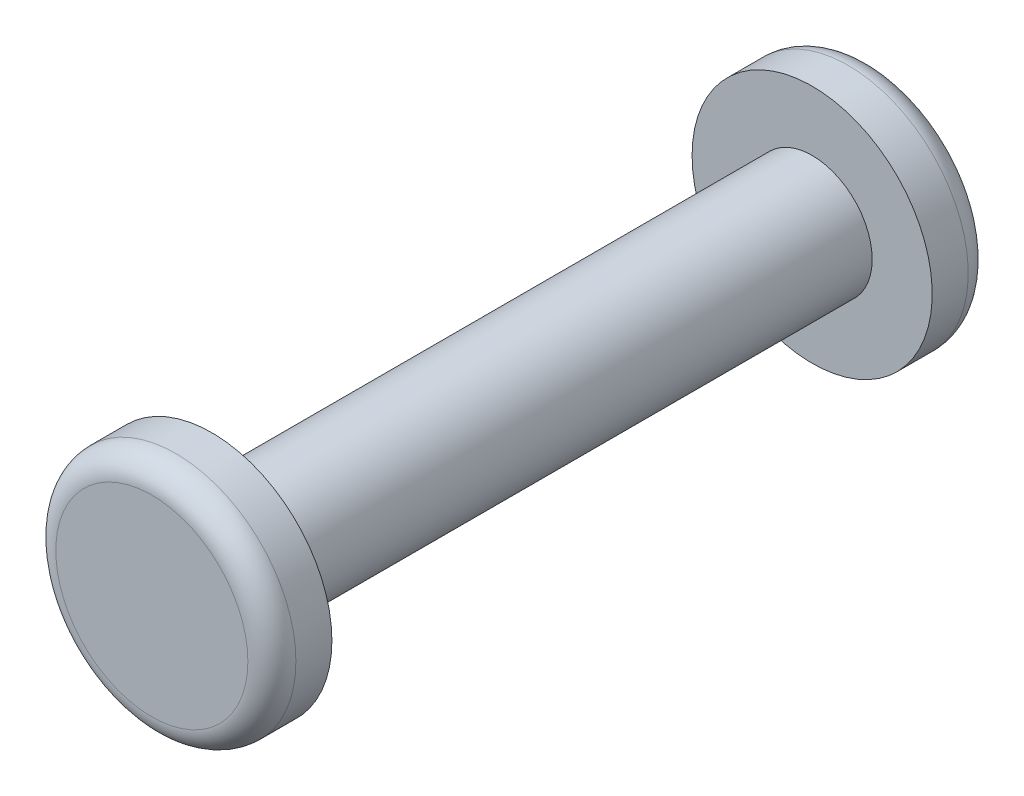
from build123d import *

# Parameters (mm, degrees)
SKETCH1_R           = 5
BOSS_EXTRUDE1_DEPTH = 25
SKETCH2_R           = 10
BOSS_EXTRUDE2_DEPTH = 5
SKETCH3_R           = 10
BOSS_EXTRUDE3_DEPTH = 5
FILLET1_R           = 2
FILLET2_R           = 2


with BuildPart() as part:
    # Sketch1 → Boss-Extrude1 (new body, symmetric)
    with BuildSketch(Plane.XY):
        Circle(SKETCH1_R)
    extrude(amount=BOSS_EXTRUDE1_DEPTH, both=True)

    # Sketch2 → Boss-Extrude2 (add)
    with BuildSketch(Plane.XY.offset(25)):
        Circle(SKETCH2_R)
    extrude(amount=BOSS_EXTRUDE2_DEPTH)

    # Sketch3 → Boss-Extrude3 (add)
    with BuildSketch(Plane(origin=(0, 0, -25), x_dir=(-1, 0, 0), z_dir=(0, 0, -1))):
        Circle(SKETCH3_R)
    extrude(amount=BOSS_EXTRUDE3_DEPTH)

    # Fillet1
    fillet1_edges = [part.edges().sort_by_distance(p)[0] for p in [
        (-10, 0, 30),
    ]]
    fillet(fillet1_edges, radius=FILLET1_R)

    # Fillet2
    fillet2_edges = [part.edges().sort_by_distance(p)[0] for p in [
        (10, 0, -30),
    ]]
    fillet(fillet2_edges, radius=FILLET2_R)


solid = part.part
